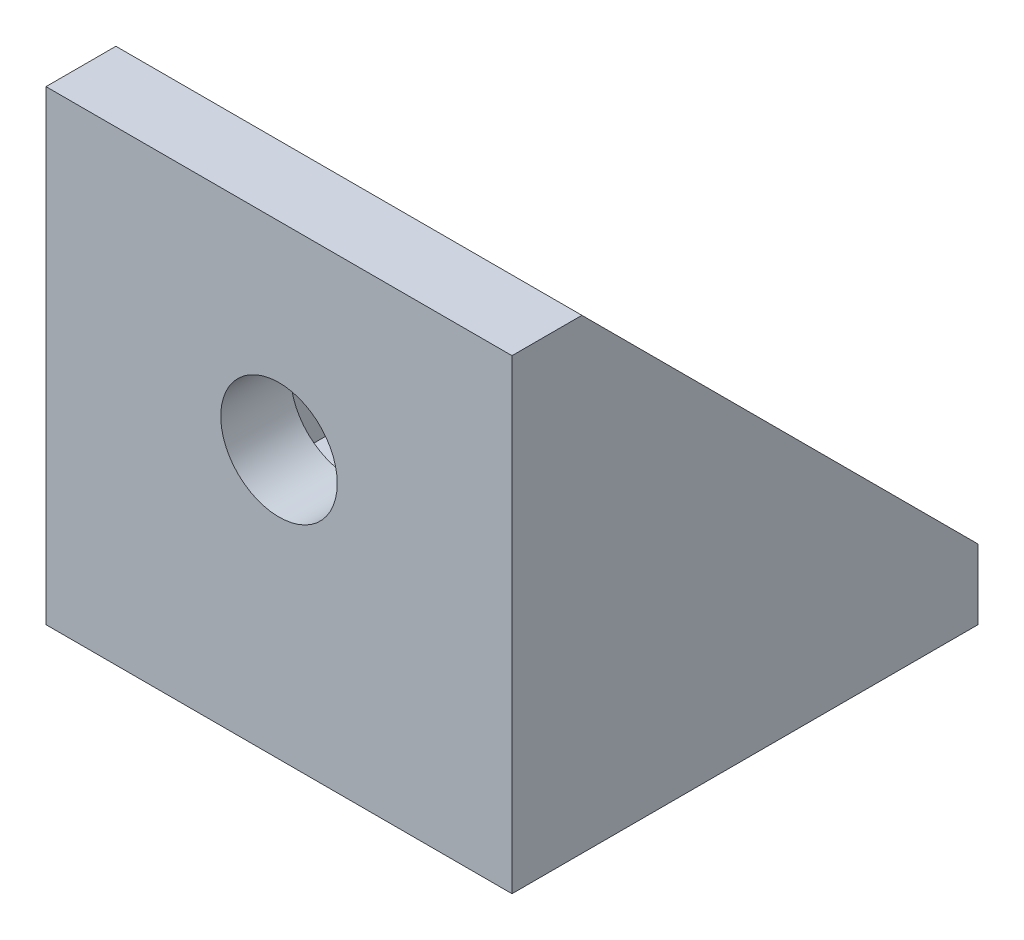
from build123d import *

# Parameters (mm, degrees)
CROQUIS1_W                 = 20
CROQUIS1_H                 = 20
SALIENTE_EXTRUIR1_DEPTH    = 3
SALIENTE_EXTRUIR2_START    = 10
CROQUIS3_W                 = 20
CROQUIS3_H                 = 20
SALIENTE_EXTRUIR2_DEPTH    = 3
SALIENTE_EXTRUIR3_START    = 10
SALIENTE_EXTRUIR3_DEPTH    = 2
SALIENTE_EXTRUIR4_START    = -10
SALIENTE_EXTRUIR4_DEPTH    = 2
CROQUIS6_R                 = 2.5
CORTAR_EXTRUIR3_DEPTH      = 21
CORTAR_EXTRUIR3_DEPTH_BACK = 1
CROQUIS7_R                 = 2.5
CORTAR_EXTRUIR4_DEPTH      = 11
CORTAR_EXTRUIR4_DEPTH_BACK = 11


with BuildPart() as part:
    # Croquis1 → Saliente-Extruir1 (new body)
    with BuildSketch(Plane(origin=(0, 0, 0), x_dir=(1, 0, 0), z_dir=(0, 1, 0))):
        Rectangle(CROQUIS1_W, CROQUIS1_H)
    extrude(amount=SALIENTE_EXTRUIR1_DEPTH)

    # Croquis3 → Saliente-Extruir2 (add)
    with BuildSketch(Plane.XY.offset(SALIENTE_EXTRUIR2_START)):
        with Locations((0, 10)):
            Rectangle(CROQUIS3_W, CROQUIS3_H)
    extrude(amount=-SALIENTE_EXTRUIR2_DEPTH)

    # Croquis4 → Saliente-Extruir3 (add)
    with BuildSketch(Plane(origin=(0, 0, 0), x_dir=(0, 0, -1), z_dir=(1, 0, 0)).offset(SALIENTE_EXTRUIR3_START)):
        Polygon((-7, 20), (10, 3), (-7, 3), align=None)
    extrude(amount=-SALIENTE_EXTRUIR3_DEPTH)

    # Croquis8 → Saliente-Extruir4 (add)
    with BuildSketch(Plane(origin=(0, 0, 0), x_dir=(0, 0, -1), z_dir=(1, 0, 0)).offset(SALIENTE_EXTRUIR4_START)):
        Polygon((10, 3), (-7, 20), (-7, 3), align=None)
    extrude(amount=SALIENTE_EXTRUIR4_DEPTH)

    # Croquis6 → Cortar-Extruir3 (cut, two sides)
    with BuildSketch(Plane(origin=(0, 0, 0), x_dir=(1, 0, 0), z_dir=(0, 1, 0))) as cortar_extruir3_sk:
        with Locations((0, 1.5)):
            Circle(CROQUIS6_R)
    extrude(amount=CORTAR_EXTRUIR3_DEPTH, mode=Mode.SUBTRACT)
    extrude(cortar_extruir3_sk.sketch, amount=-CORTAR_EXTRUIR3_DEPTH_BACK, mode=Mode.SUBTRACT)

    # Croquis7 → Cortar-Extruir4 (cut, two sides)
    with BuildSketch(Plane.XY) as cortar_extruir4_sk:
        with Locations((0, 11.5)):
            Circle(CROQUIS7_R)
    extrude(amount=CORTAR_EXTRUIR4_DEPTH, mode=Mode.SUBTRACT)
    extrude(cortar_extruir4_sk.sketch, amount=-CORTAR_EXTRUIR4_DEPTH_BACK, mode=Mode.SUBTRACT)


solid = part.part
